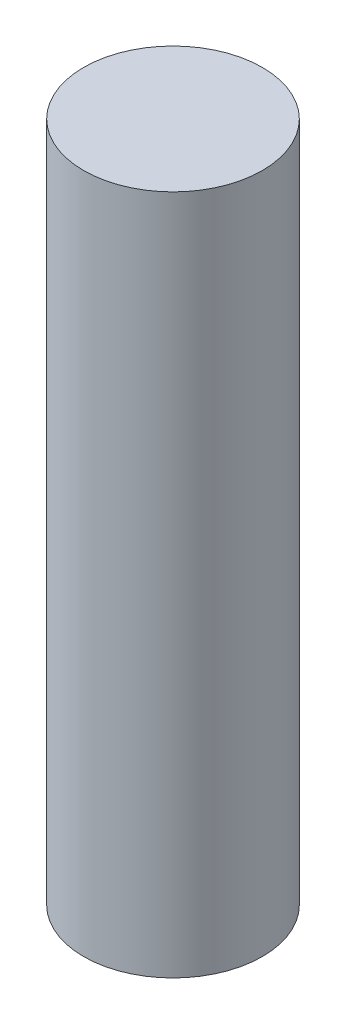
from build123d import *

# Parameters (mm, degrees)
SKETCH1_R           = 1.05
BOSS_EXTRUDE1_DEPTH = 8


with BuildPart() as part:
    # Sketch1 → Boss-Extrude1 (new body)
    with BuildSketch(Plane(origin=(0, 0, 0), x_dir=(1, 0, 0), z_dir=(0, 1, 0))):
        Circle(SKETCH1_R)
    extrude(amount=BOSS_EXTRUDE1_DEPTH)


solid = part.part
